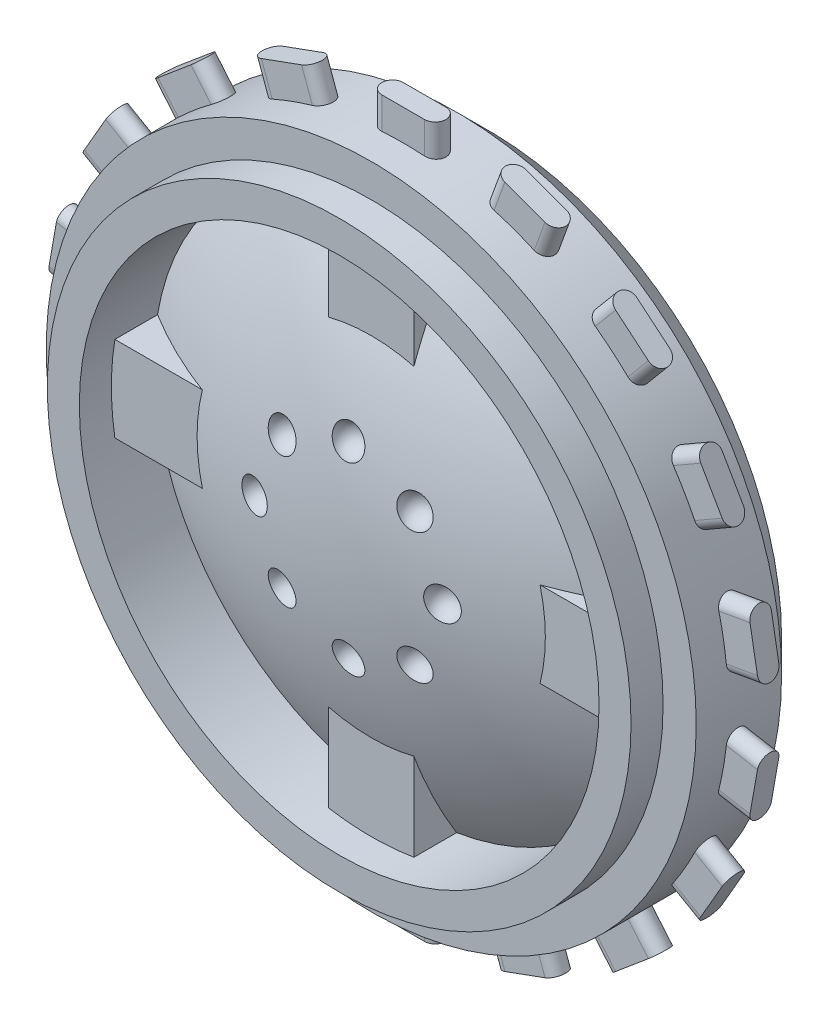
from build123d import *

# Parameters (mm, degrees)
BOSS_EXTRUDE1_DEPTH = 4.84124
CIRPATTERN1_COUNT   = 18
BOSS_EXTRUDE2_DEPTH = 3.43916
CIRPATTERN2_COUNT   = 8


with BuildPart() as part:
    # Sketch1 → Revolve1 (revolve)
    with BuildSketch(Plane(origin=(0, 0, 0), x_dir=(0, 0, -1), z_dir=(1, 0, 0))):
        with BuildLine():
            Line((-5.64642, 0), (0.80772, 0))
            Line((0.80772, 0), (0.80772, 4.8387))
            Line((0.80772, 4.8387), (5.64642, 4.8387))
            Line((5.64642, 4.8387), (5.64642, 22.14118))
            Line((5.64642, 22.14118), (3.2258, 24.5618))
            Line((3.2258, 24.5618), (-3.2258, 24.5618))
            Line((-3.2258, 24.5618), (-3.2258, 22.05736))
            Line((-3.2258, 22.05736), (-5.64642, 22.05736))
            Line((-5.64642, 22.05736), (-5.64642, 19.63928))
            Line((-5.64642, 19.63928), (-0.000387195, 19.63928))
            ThreePointArc((-0.000387195, 19.63928), (-4.206893345, 10.217374973), (-5.64642, 0))
        make_face()
    revolve(axis=Axis((0, 0, 5.64642), (0, 0, -1)))

    # Sketch3 → Boss-Extrude1 (add)
    with BuildSketch(Plane(origin=(0, 22.05736, 0), x_dir=(1, 0, 0), z_dir=(0, 1, 0))):
        with BuildLine():
            Line((-1.6129, 0.80772), (1.6129, 0.80772))
            ThreePointArc((1.6129, 0.80772), (2.42062, 0), (1.6129, -0.80772))
            Line((1.6129, -0.80772), (-1.6129, -0.80772))
            ThreePointArc((-1.6129, -0.80772), (-2.42062, 0), (-1.6129, 0.80772))
        make_face()
    boss_extrude1 = extrude(amount=BOSS_EXTRUDE1_DEPTH)

    # CirPattern1: Boss-Extrude1 ×18 about axis
    cirpattern1_axis = Axis((0, 0, 0), (0, 0, 1))
    for i in range(1, CIRPATTERN1_COUNT):
        add(boss_extrude1.rotate(cirpattern1_axis, i * 360 / CIRPATTERN1_COUNT))

    # Sketch4 → Boss-Extrude2 (add)
    with BuildSketch(Plane.XY.offset(3.2258)):
        Polygon((-3.2258, 3.2258), (-3.2258, 20.458193863), (3.2258, 20.458193863), (3.2258, 3.2258), (20.62308586, 3.2258), (20.62308586, -3.2258), (3.2258, -3.2258), (3.2258, -20.458193863), (-3.2258, -20.458193863), (-3.2258, -3.2258), (-20.62308586, -3.2258), (-20.62308586, 3.2258), align=None)
    extrude(amount=-BOSS_EXTRUDE2_DEPTH)

    # Sketch5 → Cut-Revolve1 (revolve, cut)
    with BuildSketch(Plane.XY.offset(4.96316)):
        with BuildLine():
            Line((-1.21412, 7.10438), (1.21412, 7.10438))
            ThreePointArc((1.21412, 7.10438), (0, 8.3185), (-1.21412, 7.10438))
        make_face()
    cut_revolve1 = revolve(axis=Axis((-1.21412, 7.10438, 4.96316), (1, 0, 0)), mode=Mode.SUBTRACT)

    # CirPattern2: Cut-Revolve1 ×8 about axis
    cirpattern2_axis = Axis((0, 0, 0), (0, 0, 1))
    for i in range(1, CIRPATTERN2_COUNT):
        add(cut_revolve1.rotate(cirpattern2_axis, i * 360 / CIRPATTERN2_COUNT), mode=Mode.SUBTRACT)


solid = part.part
